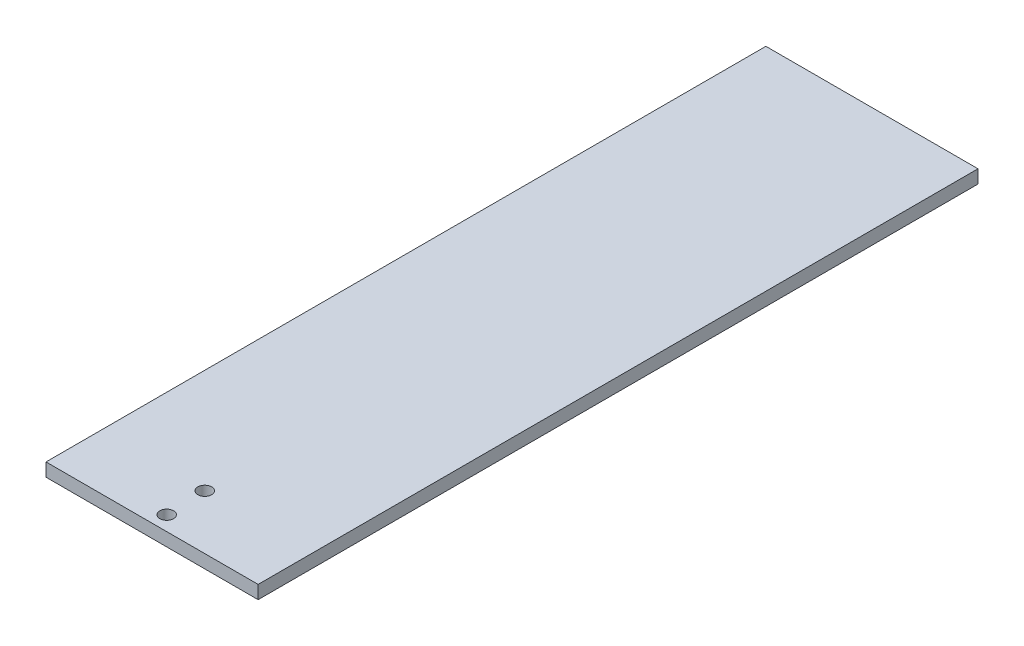
from build123d import *

# Parameters (mm, degrees)
SKETCH1_W                = 101.6
SKETCH1_H                = 344.8
BOSS_EXTRUDE1_DEPTH      = 6.35
M6_CLEARANCE_HOLE1_D     = 6.6
M6_CLEARANCE_HOLE1_DEPTH = 12.4
M6_CLEARANCE_HOLE1_TIP   = 1.982840043


with BuildPart() as part:
    # Sketch1 → Boss-Extrude1 (new body)
    with BuildSketch(Plane(origin=(0, 0, 0), x_dir=(1, 0, 0), z_dir=(0, 1, 0))):
        with Locations((50.8, 172.4)):
            Rectangle(SKETCH1_W, SKETCH1_H)
    extrude(amount=BOSS_EXTRUDE1_DEPTH)

    # M6 Clearance Hole1
    with Locations(Plane(origin=(50.000704492, 6.35, -26.033224285), x_dir=(0, 0, 1), z_dir=(0, 1, 0))):
        with Locations((0, 0), (19.033224285, 0.799295508)):
            Hole(M6_CLEARANCE_HOLE1_D / 2, depth=M6_CLEARANCE_HOLE1_DEPTH)
            with Locations((0, 0, -(M6_CLEARANCE_HOLE1_DEPTH + M6_CLEARANCE_HOLE1_TIP / 2))):  # 118° drill point
                Cone(0, M6_CLEARANCE_HOLE1_D / 2, M6_CLEARANCE_HOLE1_TIP, mode=Mode.SUBTRACT)


solid = part.part
